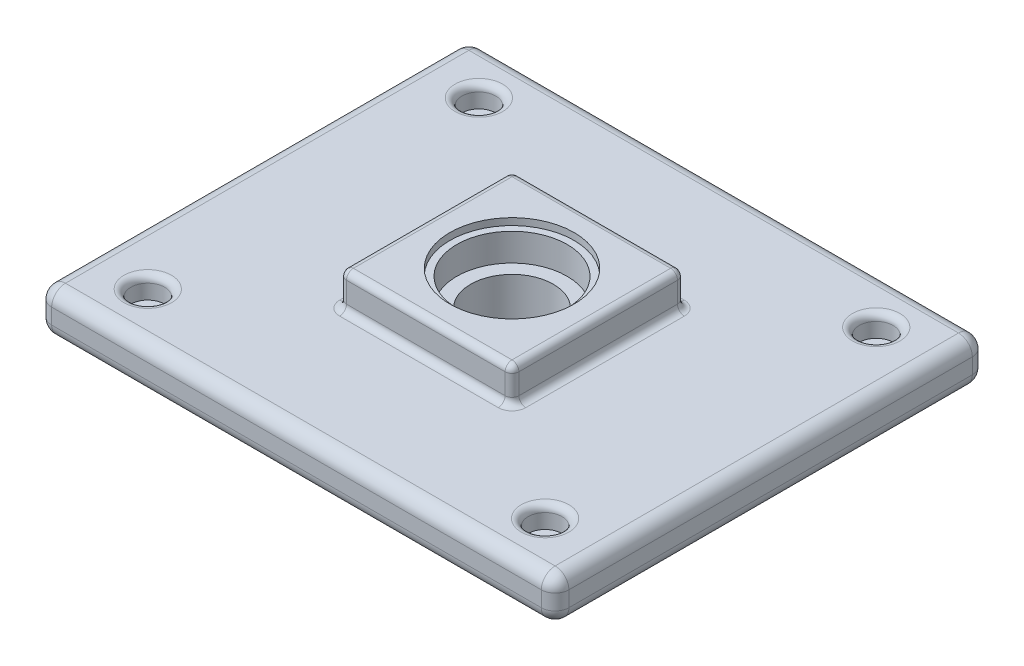
from build123d import *

# Parameters (mm, degrees)
SKETCH1_W           = 600
SKETCH1_H           = 500
BOSS_EXTRUDE1_DEPTH = 50
SKETCH2_R           = 19.6
CUT_EXTRUDE1_DEPTH  = 25
SCALE1_SCALE        = 0.125
FILLET4_R           = 1
SKETCH3_W           = 25
SKETCH3_H           = 25
BOSS_EXTRUDE2_DEPTH = 5
SKETCH4_R           = 9
CUT_EXTRUDE2_DEPTH  = 1
SKETCH5_R           = 8
CUT_EXTRUDE3_DEPTH  = 4
SKETCH6_R           = 6
CUT_EXTRUDE4_DEPTH  = 7.25
FILLET6_R           = 1
FILLET7_R           = 2


with BuildPart() as part:
    # Sketch1 → Boss-Extrude1 (new body)
    with BuildSketch(Plane(origin=(0, 0, 0), x_dir=(1, 0, 0), z_dir=(0, 1, 0))):
        Rectangle(SKETCH1_W, SKETCH1_H)
    extrude(amount=BOSS_EXTRUDE1_DEPTH)

    # Sketch2 → Cut-Extrude1 (cut)
    with BuildSketch(Plane(origin=(0, 50, 0), x_dir=(1, 0, 0), z_dir=(0, 1, 0))):
        with Locations((-230.466383879, -192.055319899)):
            Circle(SKETCH2_R)
        with Locations((230.466383879, 192.055319899)):
            Circle(SKETCH2_R)
        with Locations((230.466383879, -192.055319899)):
            Circle(SKETCH2_R)
        with Locations((-230.466383879, 192.055319899)):
            Circle(SKETCH2_R)
    extrude(amount=-CUT_EXTRUDE1_DEPTH, mode=Mode.SUBTRACT)


with BuildPart() as part_1:
    # Scale1: scaled about (0, 24.898611392, 0)
    add(part.part.scale(SCALE1_SCALE).moved(Location((0, 21.786284968, 0))))

    # Fillet4
    fillet4_edges = [part_1.edges().sort_by_distance(p)[0] for p in [
        (-31.258297985, 28.036284968, -24.006914987),
        (26.358297985, 28.036284968, 24.006914987),
        (26.358297985, 28.036284968, -24.006914987),
        (-31.258297985, 28.036284968, 24.006914987),
    ]]
    fillet(fillet4_edges, radius=FILLET4_R)

    # Sketch3 → Boss-Extrude2 (add)
    with BuildSketch(Plane(origin=(0, 21.786284968, 0), x_dir=(-1, 0, 0), z_dir=(0, -1, 0))):
        Rectangle(SKETCH3_W, SKETCH3_H)
    boss_extrude2 = extrude(amount=BOSS_EXTRUDE2_DEPTH)

    # Sketch4 → Cut-Extrude2 (cut)
    with BuildSketch(Plane.XZ.offset(-16.786284968)):
        Circle(SKETCH4_R)
    cut_extrude2 = extrude(amount=-CUT_EXTRUDE2_DEPTH, mode=Mode.SUBTRACT)

    # Sketch5 → Cut-Extrude3 (cut)
    with BuildSketch(Plane(origin=(0, 17.786284968, 0), x_dir=(-1, 0, 0), z_dir=(0, -1, 0))):
        Circle(SKETCH5_R)
    cut_extrude3 = extrude(amount=-CUT_EXTRUDE3_DEPTH, mode=Mode.SUBTRACT)

    # Sketch6 → Cut-Extrude4 (cut, through all)
    with BuildSketch(Plane(origin=(0, 21.786284968, 0), x_dir=(-1, 0, 0), z_dir=(0, -1, 0))):
        Circle(SKETCH6_R)
    extrude(amount=-CUT_EXTRUDE4_DEPTH, mode=Mode.SUBTRACT)

    # Mirror1: Boss-Extrude2, Cut-Extrude2, Cut-Extrude3 across plane
    add(boss_extrude2.mirror(Plane.ZX.offset(24.911284968)))
    add(cut_extrude2.mirror(Plane.ZX.offset(24.911284968)), mode=Mode.SUBTRACT)
    add(cut_extrude3.mirror(Plane.ZX.offset(24.911284968)), mode=Mode.SUBTRACT)

    # Fillet6
    fillet6_edges = [part_1.edges().sort_by_distance(p)[0] for p in [
        (-12.5, 21.786284968, 0),
        (-12.5, 19.286284968, 12.5),
        (0, 21.786284968, -12.5),
        (-12.5, 19.286284968, -12.5),
        (12.5, 21.786284968, 0),
        (12.5, 19.286284968, -12.5),
        (0, 21.786284968, 12.5),
        (12.5, 19.286284968, 12.5),
        (-12.5, 16.786284968, 0),
        (0, 16.786284968, -12.5),
        (12.5, 16.786284968, 0),
        (0, 16.786284968, 12.5),
        (-12.5, 33.036284968, 0),
        (-12.5, 30.536284968, -12.5),
        (0, 33.036284968, 12.5),
        (-12.5, 30.536284968, 12.5),
        (12.5, 33.036284968, 0),
        (12.5, 30.536284968, 12.5),
        (0, 33.036284968, -12.5),
        (12.5, 30.536284968, -12.5),
        (-12.5, 28.036284968, 0),
        (0, 28.036284968, -12.5),
        (12.5, 28.036284968, 0),
        (0, 28.036284968, 12.5),
    ]]
    fillet(fillet6_edges, radius=FILLET6_R)

    # Fillet7
    fillet7_edges = [part_1.edges().sort_by_distance(p)[0] for p in [
        (37.5, 28.036284968, 0),
        (0, 28.036284968, -31.25),
        (-37.5, 28.036284968, 0),
        (0, 21.786284968, -31.25),
        (37.5, 21.786284968, 0),
        (0, 21.786284968, 31.25),
        (-37.5, 21.786284968, 0),
        (-37.5, 24.911284968, -31.25),
        (37.5, 24.911284968, -31.25),
        (37.5, 24.911284968, 31.25),
        (-37.5, 24.911284968, 31.25),
        (0, 28.036284968, 31.25),
    ]]
    fillet(fillet7_edges, radius=FILLET7_R)


solid = part_1.part
